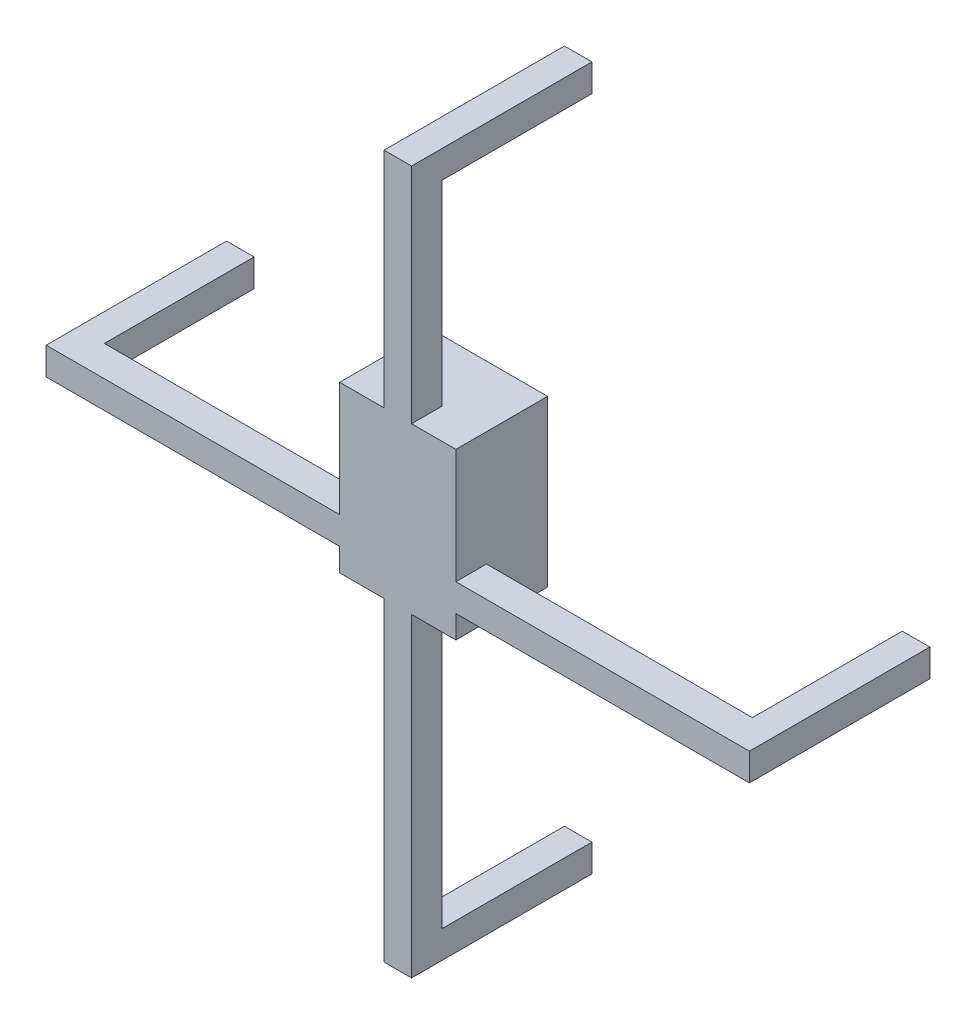
from build123d import *

# Parameters (mm, degrees)
BOSS_EXTRUDE7_DEPTH       = 2.25
BOSS_EXTRUDE7_DEPTH_BACK  = 2.25
BOSS_EXTRUDE10_DEPTH      = 10
BOSS_EXTRUDE12_DEPTH      = 2.25
BOSS_EXTRUDE12_DEPTH_BACK = 2.25
SKETCH11_W                = 19
SKETCH11_H                = 27
BOSS_EXTRUDE13_DEPTH      = 5
SKETCH12_W                = 148.824805779
SKETCH12_H                = 155.89300236
CUT_EXTRUDE1_DEPTH        = 2


with BuildPart() as part:
    # Sketch8 → Boss-Extrude7 (new body, two sides)
    with BuildSketch(Plane(origin=(0, 2.5, 0), x_dir=(1, 0, 0), z_dir=(0, 1, 0))) as boss_extrude7_sk:
        Polygon((-57.5, -4), (57.5, -4), (57.5, 27.5), (53, 27.5), (53, 1), (-53, 1), (-53, 27.5), (-57.5, 27.5), align=None)
    extrude(amount=BOSS_EXTRUDE7_DEPTH)
    extrude(boss_extrude7_sk.sketch, amount=-BOSS_EXTRUDE7_DEPTH_BACK)

    # Sketch10 → Boss-Extrude10 (add)
    with BuildSketch(Plane(origin=(0, 0, -1), x_dir=(-1, 0, 0), z_dir=(0, 0, -1))):
        Polygon((6.5, 20.5), (-6.5, 20.5), (-6.5, -2.5), (-6.5, -3.5), (-9.5, -3.5), (-9.5, -2.5), (-9.5, 23.5), (9.5, 23.5), (9.5, -2.5), (9.5, -3.5), (6.5, -3.5), (6.5, -2.5), align=None)
    extrude(amount=BOSS_EXTRUDE10_DEPTH)

    # Sketch6 → Boss-Extrude12 (add, two sides)
    with BuildSketch(Plane(origin=(0, 0, 0), x_dir=(0, 0, -1), z_dir=(1, 0, 0))) as boss_extrude12_sk:
        Polygon((27.5, 55.5), (1, 55.5), (1, -50.5), (27.5, -50.5), (27.5, -55), (-4, -55), (-4, 60), (27.5, 60), align=None)
    extrude(amount=BOSS_EXTRUDE12_DEPTH)
    extrude(boss_extrude12_sk.sketch, amount=-BOSS_EXTRUDE12_DEPTH_BACK)

    # Sketch11 → Boss-Extrude13 (add)
    with BuildSketch(Plane.XY.offset(-1)):
        with Locations((0, 10)):
            Rectangle(SKETCH11_W, SKETCH11_H)
    extrude(amount=BOSS_EXTRUDE13_DEPTH)

    # Sketch12 → Cut-Extrude1 (cut)
    with BuildSketch(Plane(origin=(0, 0, -27.5), x_dir=(-1, 0, 0), z_dir=(0, 0, -1))):
        with Locations((-7.264535374, 8.488333214)):
            Rectangle(SKETCH12_W, SKETCH12_H)
    extrude(amount=-CUT_EXTRUDE1_DEPTH, mode=Mode.SUBTRACT)


solid = part.part
